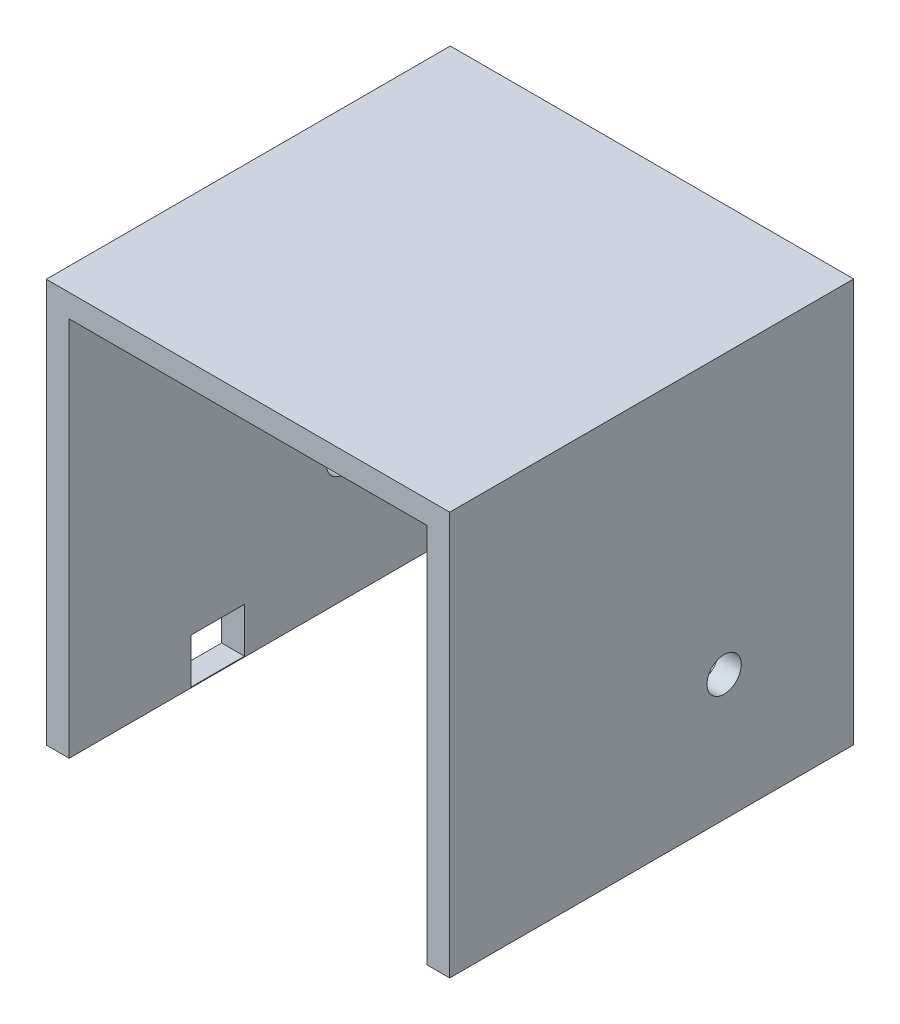
from build123d import *

# Parameters (mm, degrees)
BOSS_EXTRUDE1_DEPTH     = 530
SKETCH2_R               = 22.5
CUT_EXTRUDE1_DEPTH      = 1
CUT_EXTRUDE1_DEPTH_BACK = 530.3
SKETCH3_W               = 70
SKETCH3_H               = 59
CUT_EXTRUDE2_DEPTH      = 220


with BuildPart() as part:
    # Sketch1 → Boss-Extrude1 (new body)
    with BuildSketch(Plane.XY):
        Polygon((-248.875659786, -247.380437864), (-278.875659786, -247.380437864), (-278.875659786, 281.919562136), (250.424340214, 281.919562136), (250.424340214, -247.380437864), (220.424340214, -247.380437864), (220.424340214, 251.919562136), (-248.875659786, 251.919562136), align=None)
    extrude(amount=BOSS_EXTRUDE1_DEPTH)

    # Sketch2 → Cut-Extrude1 (cut, two sides)
    with BuildSketch(Plane(origin=(250.424340214, 0, 0), x_dir=(0, 0, -1), z_dir=(1, 0, 0))) as cut_extrude1_sk:
        with Locations((-170, -82.380437864)):
            Circle(SKETCH2_R)
    extrude(amount=CUT_EXTRUDE1_DEPTH, mode=Mode.SUBTRACT)
    extrude(cut_extrude1_sk.sketch, amount=-CUT_EXTRUDE1_DEPTH_BACK, mode=Mode.SUBTRACT)

    # Sketch3 → Cut-Extrude2 (cut)
    with BuildSketch(Plane.ZY.offset(278.875659786)):
        with Locations((335, -216.880437864)):
            Rectangle(SKETCH3_W, SKETCH3_H)
    extrude(amount=-CUT_EXTRUDE2_DEPTH, mode=Mode.SUBTRACT)


solid = part.part
